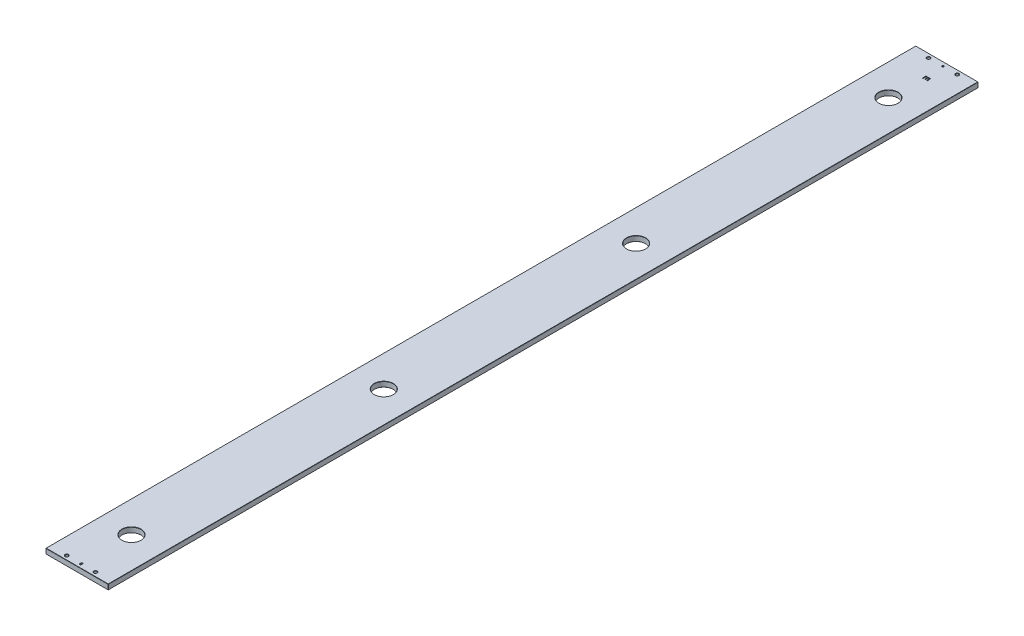
from build123d import *

# Parameters (mm, degrees)
SKETCH1_W                                     = 152.4
SKETCH1_H                                     = 12.7
EXTRUDE_THIN1_DEPTH                           = 1062
CHAMFER1_SIZE                                 = 0.5
CBORE_FOR_1_4_SOCKET_HEAD_CAP_SCREW1_AT_COUNT = 2
CBORE_FOR_1_4_SOCKET_HEAD_CAP_SCREW1_AT_PITCH = 70
EXTRUDE1_REACH                                = 14.7
SKETCH6_R                                     = 23
GUIDE_DIAMETER_DEPTH                          = 13.7
CHAMFER2_SIZE                                 = 0.5
LPATTERN1_COUNT                               = 4
LPATTERN1_PITCH                               = 616
CHAMFER2_OF_LPATTERN1_SIZE                    = 0.5
CHAMFER3_SIZE                                 = 0.5
CUT_EXTRUDE1_DEPTH                            = 2


with BuildPart() as part:
    # Sketch1 → Extrude-Thin1 (new body, symmetric)
    with BuildSketch(Plane.XY):
        Rectangle(SKETCH1_W, SKETCH1_H)
    extrude(amount=EXTRUDE_THIN1_DEPTH, both=True)

    # Chamfer1
    chamfer1_edges = [part.edges().sort_by_distance(p)[0] for p in [
        (0, 6.35, 1062),
        (-76.2, 0, 1062),
        (-76.2, 0, -1062),
        (0, -6.35, 1062),
        (0, 6.35, -1062),
        (76.2, 0, -1062),
        (0, -6.35, -1062),
        (-76.2, -6.35, 0),
        (-76.2, 6.35, 0),
        (76.2, 6.35, 0),
        (76.2, -6.35, 0),
        (76.2, 0, 1062),
    ]]
    chamfer(chamfer1_edges, length=CHAMFER1_SIZE)

    # Sketch3 → CBORE for 1/4 Socket Head Cap Screw1 (revolve, cut)
    with BuildSketch(Plane(origin=(-35, -6.35, -1052), x_dir=(0, 0, -1), z_dir=(1, 0, 0))):
        Polygon((0, 0), (0, 12.7), (4.20624, 12.7), (3.57124, 12.065), (3.57124, 6.35), (5.55625, 6.35), (5.55625, 0), align=None)
    cbore_for_1_4_socket_head_cap_screw1 = revolve(axis=Axis((-35, -12.7, -1052), (0, 1, 0)), mode=Mode.SUBTRACT)

    # CBORE for 1/4 Socket Head Cap Screw1 at: CBORE for 1/4 Socket Head Cap Screw1 ×2
    with Locations(*[(i * CBORE_FOR_1_4_SOCKET_HEAD_CAP_SCREW1_AT_PITCH, 0, 0) for i in range(1, CBORE_FOR_1_4_SOCKET_HEAD_CAP_SCREW1_AT_COUNT)]):
        add(cbore_for_1_4_socket_head_cap_screw1, mode=Mode.SUBTRACT)

    # Sketch4 → 1/8 (0.125) Diameter Hole1 (revolve, cut)
    with BuildSketch(Plane(origin=(0, -6.35, -1052), x_dir=(0, 0, -1), z_dir=(1, 0, 0))):
        Polygon((0, 0), (0, 12.7), (2.2225, 12.7), (1.6002, 12.0777), (1.6002, 0.6223), (2.2225, 0), align=None)
    revolve(axis=Axis((0, -12.7, -1052), (0, 1, 0)), mode=Mode.SUBTRACT)

    # Mirror1: CBORE for 1/4 Socket Head Cap Screw1 across plane
    add(cbore_for_1_4_socket_head_cap_screw1.mirror(Plane.XY), mode=Mode.SUBTRACT)

    # Mirror1 copy 1 sketch → Mirror1 copy 1 (revolve, cut)
    with BuildSketch(Plane(origin=(35, -6.35, 1052), x_dir=(0, 0, 1), z_dir=(1, 0, 0))):
        Polygon((0, 0), (0, -12.7), (4.20624, -12.7), (3.57124, -12.065), (3.57124, -6.35), (5.55625, -6.35), (5.55625, 0), align=None)
    revolve(axis=Axis((35, -12.7, 1052), (0, -1, 0)), mode=Mode.SUBTRACT)

    # Sketch5 → Extrude1 (cut, up to next)
    with BuildSketch(Plane(origin=(0, 6.35, 0), x_dir=(1, 0, 0), z_dir=(0, 1, 0)), mode=Mode.PRIVATE) as extrude1_sk1:
        with BuildLine():
            Line((-1.6002, -1053.5), (-1.6002, -1050.5))
            ThreePointArc((-1.6002, -1050.5), (0, -1048.8998), (1.6002, -1050.5))
            Line((1.6002, -1050.5), (1.6002, -1053.5))
            ThreePointArc((1.6002, -1053.5), (0, -1055.1002), (-1.6002, -1053.5))
        make_face()
    extrude1_tool1 = extrude(extrude1_sk1.sketch, amount=-EXTRUDE1_REACH, mode=Mode.PRIVATE) & part.part
    add(extrude1_tool1.solids().sort_by_distance((0, 6.35, 1052))[0], mode=Mode.SUBTRACT)

    # Sketch6 → guide diameter (cut, through all)
    with BuildSketch(Plane(origin=(0, 6.35, 0), x_dir=(1, 0, 0), z_dir=(0, 1, 0))):
        with Locations(Location((0, 919, 0), (0, 0, 180))):  # turned: the seam where the file's is
            Circle(SKETCH6_R)
    guide_diameter = extrude(amount=-GUIDE_DIAMETER_DEPTH, mode=Mode.SUBTRACT)

    # Chamfer2
    chamfer2_edges = [part.edges().sort_by_distance(p)[0] for p in [
        (23, -6.35, -919),
        (23, 6.35, -919),
    ]]
    chamfer(chamfer2_edges, length=CHAMFER2_SIZE)

    # LPattern1: guide diameter ×4
    with Locations(*[(0, 0, i * LPATTERN1_PITCH) for i in range(1, LPATTERN1_COUNT)]):
        add(guide_diameter, mode=Mode.SUBTRACT)

    # Chamfer2 of LPattern1
    chamfer2_of_lpattern1_edges = [part.edges().sort_by_distance(p)[0] for p in [
        (23, -6.35, -303),
        (23, 6.35, -303),
        (23, -6.35, 313),
        (23, 6.35, 313),
        (23, -6.35, 929),
        (23, 6.35, 929),
    ]]
    chamfer(chamfer2_of_lpattern1_edges, length=CHAMFER2_OF_LPATTERN1_SIZE)

    # Chamfer3
    chamfer3_edges = [part.edges().sort_by_distance(p)[0] for p in [
        (0, 6.35, 1055.1002),
        (1.6002, 6.35, 1052),
        (0, 6.35, 1048.8998),
        (-1.6002, 6.35, 1052),
    ]]
    chamfer(chamfer3_edges, length=CHAMFER3_SIZE)

    # Sketch7 → Cut-Extrude1 (cut)
    with BuildSketch(Plane(origin=(0, 6.35, 0), x_dir=(1, 0, 0), z_dir=(0, 1, 0))):
        with BuildLine():
            Line((10.016442871, 1002.864811478), (10.016442871, 1008.301621094))
            Line((10.016442871, 1008.301621094), (7.08855957, 1008.301621094))
            Line((7.08855957, 1008.301621094), (7.08855957, 1003.295807457))
            add(Edge.make_bspline(
                [(7.08855957, 1003.295807457), (7.085272029, 1003.208940575), (7.079101125, 1003.045886399), (7.035451852, 1002.817641442), (6.955335746, 1002.62460988), (6.843536393, 1002.467570614), (6.70448491, 1002.346963747), (6.545966626, 1002.258305794), (6.364548529, 1002.206474612), (6.237339762, 1002.200801414), (6.17118824, 1002.197851219)],
                knots=[0, 0, 0, 0, 1.285293232, 2.412569968, 3.418386025, 4.354403319, 5.23810445, 6.120527863, 7.022630715, 8, 8, 8, 8], degree=3))
            add(Edge.make_bspline(
                [(6.17118824, 1002.197851219), (6.104964912, 1002.200656064), (5.977618061, 1002.206049755), (5.797214668, 1002.25982572), (5.634101786, 1002.34183535), (5.491945229, 1002.462060899), (5.377499487, 1002.6195556), (5.294517407, 1002.813274474), (5.248231883, 1003.043251768), (5.242447251, 1003.20811075), (5.239370117, 1003.295807457)],
                knots=[0, 0, 0, 0, 0.970712631, 1.866671451, 2.742370236, 3.637940775, 4.57451605, 5.578136324, 6.711690039, 8, 8, 8, 8], degree=3))
            Line((5.239370117, 1003.295807457), (5.239370117, 1008.301621094))
            Line((5.239370117, 1008.301621094), (1.849189453, 1008.301621094))
            Line((1.849189453, 1008.301621094), (1.849189453, 1002.677003174))
            add(Edge.make_bspline(
                [(1.849189453, 1002.677003174), (1.845843655, 1002.587755059), (1.839553911, 1002.419978146), (1.796273178, 1002.183378763), (1.713671661, 1001.983271463), (1.602044928, 1001.817186066), (1.461094123, 1001.68999124), (1.299501043, 1001.595310324), (1.113983026, 1001.54232453), (0.984306529, 1001.534783446), (0.91737133, 1001.530890961)],
                knots=[0, 0, 0, 0, 1.282115211, 2.410239491, 3.433544999, 4.370413449, 5.259840111, 6.137762651, 7.038767785, 8, 8, 8, 8], degree=3))
            add(Edge.make_bspline(
                [(0.91737133, 1001.530890961), (0.851993137, 1001.534651561), (0.726142864, 1001.541890558), (0.545865721, 1001.596390772), (0.387681571, 1001.690646995), (0.247310665, 1001.817205123), (0.134833927, 1001.98271475), (0.056769985, 1002.184311918), (0.008482543, 1002.419532279), (0.002943607, 1002.587655764), (0, 1002.677003174)],
                knots=[0, 0, 0, 0, 0.94634305, 1.821670557, 2.697075277, 3.594139625, 4.539053153, 5.56674892, 6.706875008, 8, 8, 8, 8], degree=3))
            Line((0, 1002.677003174), (0, 1009.197322235))
            add(Edge.make_bspline(
                [(0, 1009.197322235), (0.003403349, 1009.314873529), (0.009736608, 1009.53362358), (0.074602909, 1009.836521786), (0.180649823, 1010.088999186), (0.339573158, 1010.291217597), (0.552801999, 1010.438170066), (0.813387914, 1010.544806157), (1.127716106, 1010.601254331), (1.352976872, 1010.608974714), (1.473572845, 1010.61310791)],
                knots=[0, 0, 0, 0, 1.189944925, 2.214356848, 3.121275872, 3.943259729, 4.783004917, 5.7166381, 6.777575619, 8, 8, 8, 8], degree=3))
            Line((1.473572845, 1010.61310791), (10.392059479, 1010.61310791))
            add(Edge.make_bspline(
                [(10.392059479, 1010.61310791), (10.474780749, 1010.611163402), (10.631859192, 1010.607470999), (10.856621451, 1010.582501559), (11.056627192, 1010.533966149), (11.235432954, 1010.469602563), (11.391264364, 1010.385371213), (11.525717721, 1010.279949262), (11.633961183, 1010.150122691), (11.722671877, 1010.000765575), (11.785939946, 1009.828912547), (11.835213509, 1009.637980919), (11.859793233, 1009.424283611), (11.863628174, 1009.275222133), (11.865632324, 1009.197322235)],
                knots=[0, 0, 0, 0, 1.25760687, 2.388054849, 3.429687073, 4.379296607, 5.269270079, 6.111463577, 6.959732887, 7.823909447, 8.739278143, 9.733531743, 10.815538057, 12, 12, 12, 12], degree=3))
            Line((11.865632324, 1009.197322235), (11.865632324, 1002.864811478))
            add(Edge.make_bspline(
                [(11.865632324, 1002.864811478), (11.862265523, 1002.774764089), (11.855933206, 1002.605401979), (11.812996161, 1002.367164125), (11.730730959, 1002.166636583), (11.618324043, 1002.00251409), (11.478831829, 1001.878582005), (11.319068401, 1001.788356803), (11.138688717, 1001.73440727), (11.01123092, 1001.728799229), (10.945853195, 1001.725922661)],
                knots=[0, 0, 0, 0, 1.303543407, 2.451718649, 3.482873774, 4.417375591, 5.305837532, 6.158811619, 7.05558772, 8, 8, 8, 8], degree=3))
            add(Edge.make_bspline(
                [(10.945853195, 1001.725922661), (10.878836329, 1001.728683151), (10.748933743, 1001.734033965), (10.565169593, 1001.78908629), (10.401495053, 1001.876989185), (10.26161213, 1002.002763084), (10.148391264, 1002.166047339), (10.069867284, 1002.367823404), (10.025886735, 1002.605293266), (10.019721068, 1002.774726352), (10.016442871, 1002.864811478)],
                knots=[0, 0, 0, 0, 0.961524532, 1.863777426, 2.731626687, 3.61454628, 4.543218546, 5.563575511, 6.704588277, 8, 8, 8, 8], degree=3))
        make_face()
    extrude(amount=-CUT_EXTRUDE1_DEPTH, mode=Mode.SUBTRACT)


solid = part.part
